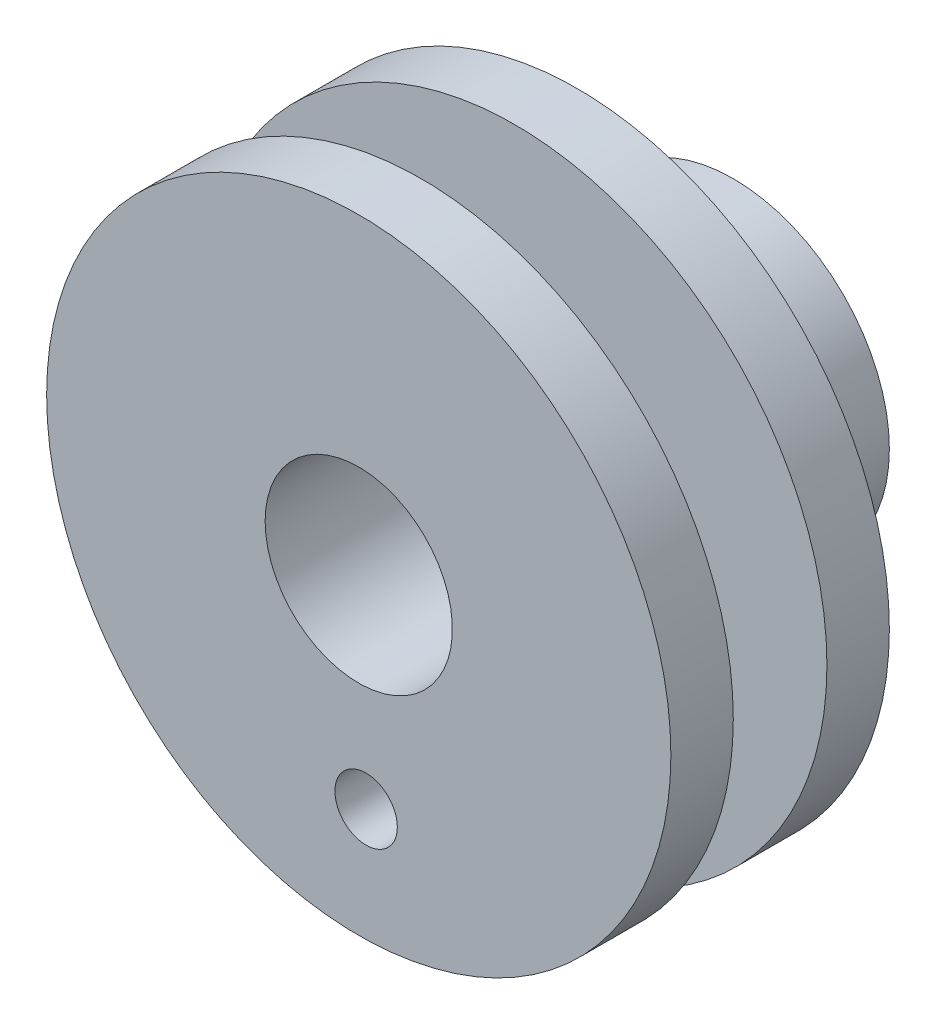
from build123d import *

# Parameters (mm, degrees)
SKETCH_1_R          = 5
SKETCH_1_R_2        = 3
EXTRUDE_1_DEPTH     = 5
SKETCH_2_R          = 10
SKETCH_2_R_2        = 3
EXTRUDE_2_DEPTH     = 2
SKETCH_3_R          = 5
EXTRUDE_3_DEPTH     = 3
SKETCH_4_R          = 10
EXTRUDE_4_DEPTH     = 2
SKETCH_5_R          = 3
CUT_EXTRUDE_1_DEPTH = 16.779733838
M3X0_5_1_REACH      = 22.665
M3X0_5_1_BORE_R     = 1.25
SKETCH_7_R          = 1
CUT_EXTRUDE_2_DEPTH = 19.547237056


with BuildPart() as part:
    # ｽｹｯﾁ1 → ﾎﾞｽ - 押し出し1 (new body)
    with BuildSketch(Plane.XY):
        Circle(SKETCH_1_R)
        Circle(SKETCH_1_R_2, mode=Mode.SUBTRACT)
    extrude(amount=EXTRUDE_1_DEPTH)

    # ｽｹｯﾁ2 → ﾎﾞｽ - 押し出し2 (add)
    with BuildSketch(Plane.XY.offset(5)):
        Circle(SKETCH_2_R)
        Circle(SKETCH_2_R_2, mode=Mode.SUBTRACT)
    extrude(amount=EXTRUDE_2_DEPTH)

    # ｽｹｯﾁ3 → ﾎﾞｽ - 押し出し3 (add)
    with BuildSketch(Plane.XY.offset(7)):
        Circle(SKETCH_3_R)
    extrude(amount=EXTRUDE_3_DEPTH)

    # ｽｹｯﾁ4 → ﾎﾞｽ - 押し出し4 (add)
    with BuildSketch(Plane.XY.offset(10)):
        Circle(SKETCH_4_R)
    extrude(amount=EXTRUDE_4_DEPTH)

    # ｽｹｯﾁ5 → ｶｯﾄ - 押し出し1 (cut, through all)
    with BuildSketch(Plane(origin=(0, 0, 7), x_dir=(-1, 0, 0), z_dir=(0, 0, -1))):
        Circle(SKETCH_5_R)
    extrude(amount=-CUT_EXTRUDE_1_DEPTH, mode=Mode.SUBTRACT)

    # M3x0.5 ねじ穴1 bore (on position points) → M3x0.5 ねじ穴1 (cut, up to next)
    with BuildSketch(Plane(origin=(0.251235543, -4.993684081, 2.143915345), x_dir=(-0.998736816219, -0.050247108654, 0), z_dir=(0.050247108654, -0.998736816219, 0)), mode=Mode.PRIVATE) as m3x0_5_1_sk1:
        Circle(M3X0_5_1_BORE_R)
    m3x0_5_1_tool1 = extrude(m3x0_5_1_sk1.sketch, amount=-M3X0_5_1_REACH, mode=Mode.PRIVATE) & part.part
    add(m3x0_5_1_tool1.solids().sort_by_distance((0.251236, -4.993684, 2.143915))[0], mode=Mode.SUBTRACT)

    # ｽｹｯﾁ7 → ｶｯﾄ - 押し出し2 (cut, through all)
    with BuildSketch(Plane.XY.offset(12)):
        with Locations((0.235884413, -6.376305987)):
            Circle(SKETCH_7_R)
    extrude(amount=-CUT_EXTRUDE_2_DEPTH, mode=Mode.SUBTRACT)


solid = part.part
